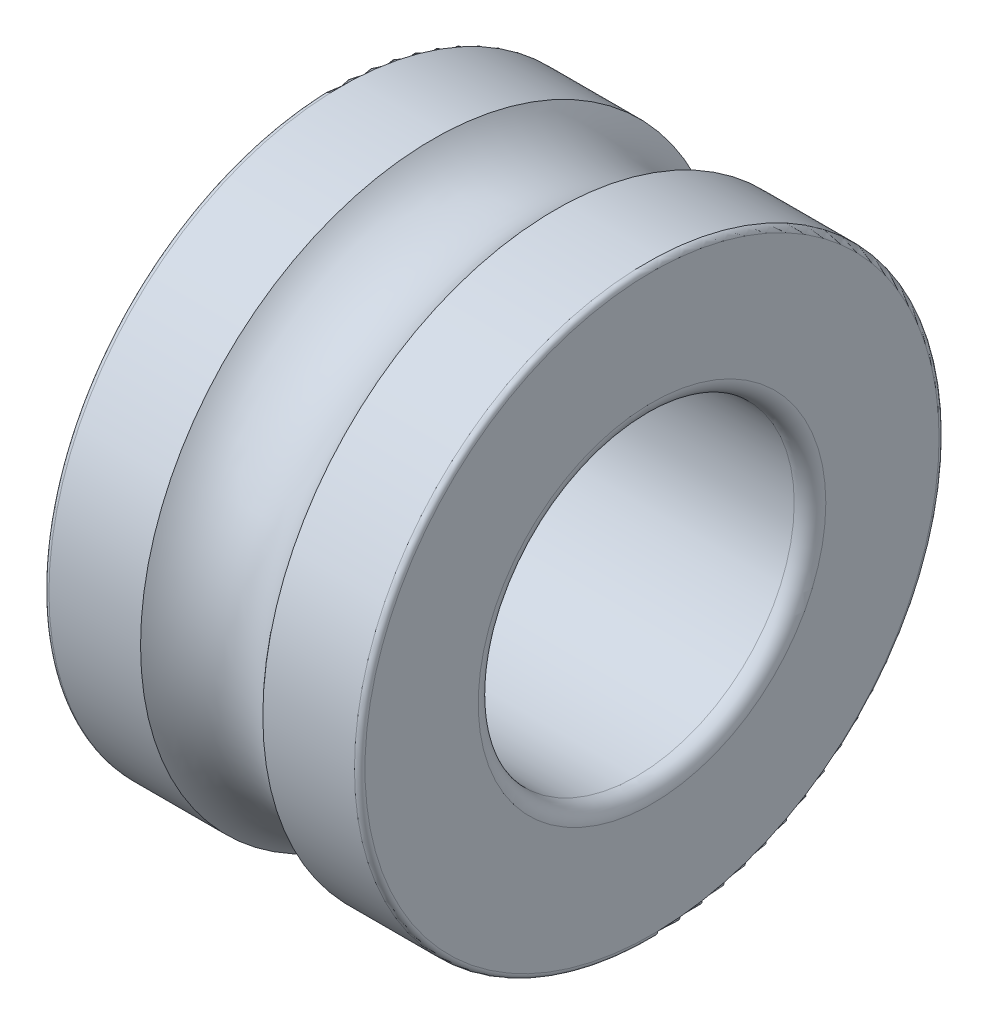
from build123d import *


with BuildPart() as part:
    # Sketch1 → Revolve1 (revolve)
    with BuildSketch(Plane.XY, mode=Mode.PRIVATE) as revolve1_sk:
        with BuildLine():
            Line((0.3, 3), (5.7, 3))
            ThreePointArc((5.7, 3), (5.912132034, 3.087867966), (6, 3.3))
            Line((6, 3.3), (6, 5.45))
            ThreePointArc((6, 5.45), (5.970710678, 5.520710678), (5.9, 5.55))
            Line((5.9, 5.55), (4.160818677, 5.55))
            ThreePointArc((4.160818677, 5.55), (3, 5), (1.839181323, 5.55))
            Line((1.839181323, 5.55), (0.1, 5.55))
            ThreePointArc((0.1, 5.55), (0.029289322, 5.520710678), (0, 5.45))
            Line((0, 5.45), (0, 3.3))
            ThreePointArc((0, 3.3), (0.087867966, 3.087867966), (0.3, 3))
        make_face()
    revolve(revolve1_sk.sketch.rotate(Axis((5.7, 0, 0), (-1, 0, 0)), 90), axis=Axis((5.7, 0, 0), (-1, 0, 0)))  # turned: the seam where the file's is


solid = part.part
